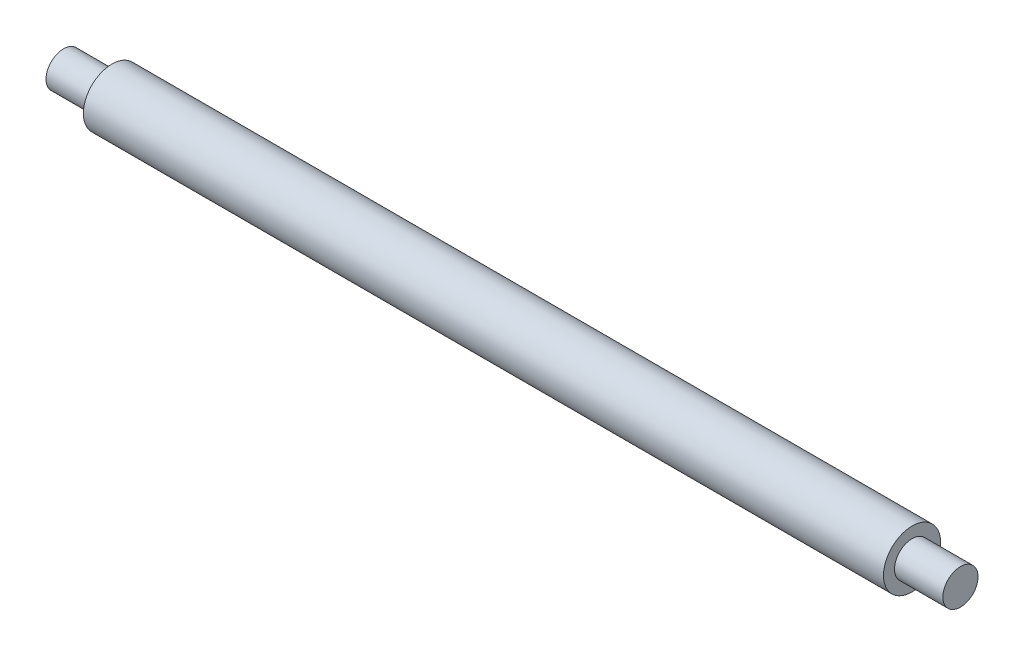
from build123d import *


with BuildPart() as part:
    # Sketch1 → Revolve1 (revolve)
    with BuildSketch(Plane.XY):
        Polygon((-148.262295082, 0), (-148.262295082, 4), (-137.262295082, 4), (-137.262295082, 6.5), (44.737704918, 6.5), (44.737704918, 4), (55.737704918, 4), (55.737704918, 0), align=None)
    revolve(axis=Axis((-165.12909355, 0, 0), (1, 0, 0)))


solid = part.part
